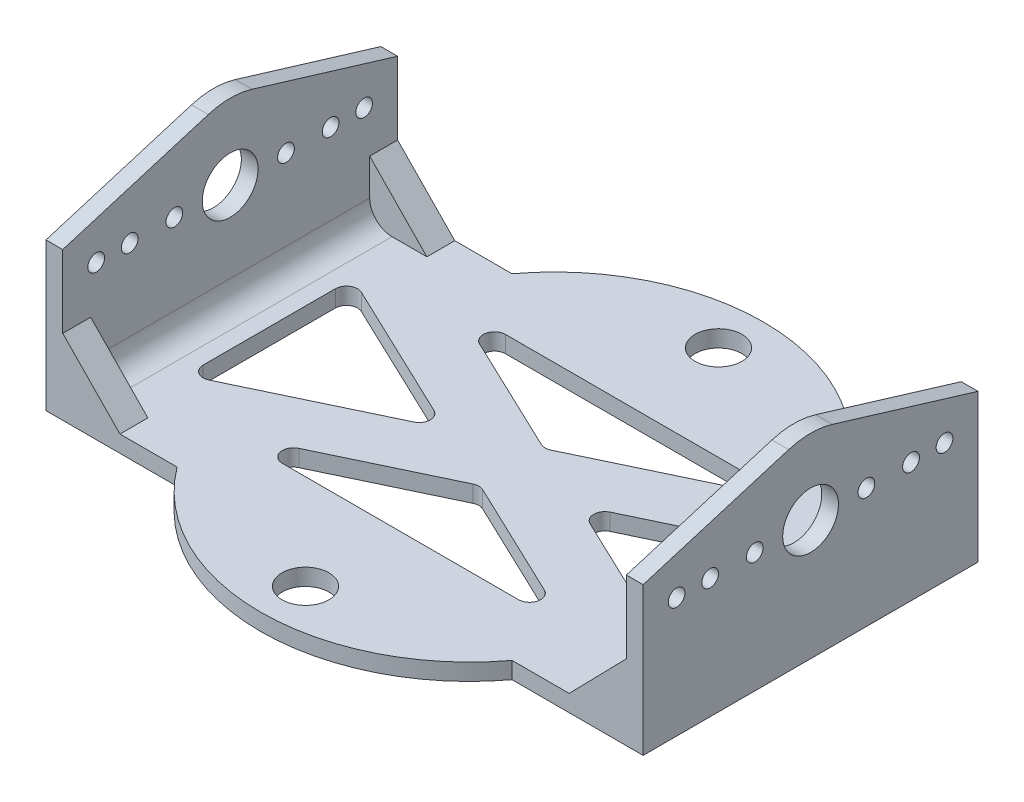
from build123d import *

# Parameters (mm, degrees)
SKETCH1_R            = 4.2
BOSS_EXTRUDE1_DEPTH  = 3
FILLET1_R            = 2
SKETCH2_R            = 1.5
SKETCH2_R_2          = 5
BOSS_EXTRUDE2_DEPTH  = 3
BOSS_EXTRUDE3_DEPTH  = 5
MIRROR3_COPY_1_DEPTH = 5
FILLET2_R            = 4


with BuildPart() as part:
    # Sketch1 → Boss-Extrude1 (new body)
    with BuildSketch(Plane(origin=(0, 0, 0), x_dir=(1, 0, 0), z_dir=(0, 1, 0))):
        with BuildLine():
            Line((-107, 60), (-107, 0))
            Line((-107, 0), (-83.5, 0))
            ThreePointArc((-83.5, 0), (-53.5, -15.042526813), (-23.5, 0))
            Line((-23.5, 0), (0, 0))
            Line((0, 0), (0, 60))
            Line((0, 60), (-23.5, 60))
            ThreePointArc((-23.5, 60), (-53.5, 75.042526813), (-83.5, 60))
            Line((-83.5, 60), (-107, 60))
        make_face()
        Polygon((-97, 45), (-65.5, 30), (-97, 15), align=None, mode=Mode.SUBTRACT)
        Polygon((-83.5, 10), (-53.5, 24.285714286), (-23.5, 10), align=None, mode=Mode.SUBTRACT)
        Polygon((-10, 15), (-41.5, 30), (-10, 45), align=None, mode=Mode.SUBTRACT)
        Polygon((-23.5, 50), (-53.5, 35.714285714), (-83.5, 50), align=None, mode=Mode.SUBTRACT)
        with BuildLine():
            ThreePointArc((-53.5, 62.8), (-57.7, 67), (-53.5, 71.2))
            ThreePointArc((-53.5, 71.2), (-49.3, 67), (-53.5, 62.8))
        make_face(mode=Mode.SUBTRACT)
        with Locations((-53.5, -7)):
            Circle(SKETCH1_R, mode=Mode.SUBTRACT)
    extrude(amount=BOSS_EXTRUDE1_DEPTH)

    # Fillet1
    fillet1_edges = [part.edges().sort_by_distance(p)[0] for p in [
        (-10, 1.5, -15),
        (-10, 1.5, -45),
        (-41.5, 1.5, -30),
        (-83.5, 1.5, -10),
        (-23.5, 1.5, -10),
        (-53.5, 1.5, -24.285714286),
        (-97, 1.5, -45),
        (-97, 1.5, -15),
        (-65.5, 1.5, -30),
        (-23.5, 1.5, -50),
        (-83.5, 1.5, -50),
        (-53.5, 1.5, -35.714285714),
    ]]
    fillet(fillet1_edges, radius=FILLET1_R)

    # Sketch2 → Boss-Extrude2 (add)
    with BuildSketch(Plane.ZY.offset(107)):
        with BuildLine():
            Line((0, 26.5), (-26.077953741, 34.417722444))
            ThreePointArc((-26.077953741, 34.417722444), (-30, 35), (-33.922046259, 34.417722444))
            Line((-33.922046259, 34.417722444), (-60, 26.5))
            Line((-60, 26.5), (-60, 3))
            Line((-60, 3), (0, 3))
            Line((0, 3), (0, 26.5))
        make_face()
        with Locations((-40, 21.5)):
            Circle(SKETCH2_R, mode=Mode.SUBTRACT)
        with Locations((-30, 21.5)):
            Circle(SKETCH2_R_2, mode=Mode.SUBTRACT)
        with Locations((-12, 21.5)):
            Circle(SKETCH2_R, mode=Mode.SUBTRACT)
        with Locations((-6, 21.5)):
            Circle(SKETCH2_R, mode=Mode.SUBTRACT)
        with Locations((-54, 21.5)):
            Circle(SKETCH2_R, mode=Mode.SUBTRACT)
        with Locations((-48, 21.5)):
            Circle(SKETCH2_R, mode=Mode.SUBTRACT)
        with Locations((-20, 21.5)):
            Circle(SKETCH2_R, mode=Mode.SUBTRACT)
    boss_extrude2 = extrude(amount=-BOSS_EXTRUDE2_DEPTH)

    # Mirror1: Boss-Extrude2 across plane
    add(boss_extrude2.mirror(Plane(origin=(-53.5, 0, 0), x_dir=(0, 0, 1), z_dir=(1, 0, 0))))

    # Sketch4 → Boss-Extrude3 (add)
    with BuildSketch(Plane.XY):
        Polygon((-104, 13.5), (-93.75, 3), (-104, 3), align=None)
    boss_extrude3 = extrude(amount=-BOSS_EXTRUDE3_DEPTH)

    # Mirror2: Boss-Extrude3 across plane
    add(boss_extrude3.mirror(Plane(origin=(-53.5, 0, 0), x_dir=(0, 0, 1), z_dir=(1, 0, 0))))

    # Mirror3: Boss-Extrude3 across plane
    add(boss_extrude3.mirror(Plane.XY.offset(-30)))

    # Mirror3 copy 1 sketch → Mirror3 copy 1 (add)
    with BuildSketch(Plane(origin=(-107, 0, -60), x_dir=(-1, 0, 0), z_dir=(0, 0, -1))):
        Polygon((-104, 13.5), (-93.75, 3), (-104, 3), align=None)
    extrude(amount=-MIRROR3_COPY_1_DEPTH)

    # Fillet2
    fillet2_edges = [part.edges().sort_by_distance(p)[0] for p in [
        (-104, 3, -30),
        (-3, 3, -30),
    ]]
    fillet(fillet2_edges, radius=FILLET2_R)


solid = part.part
